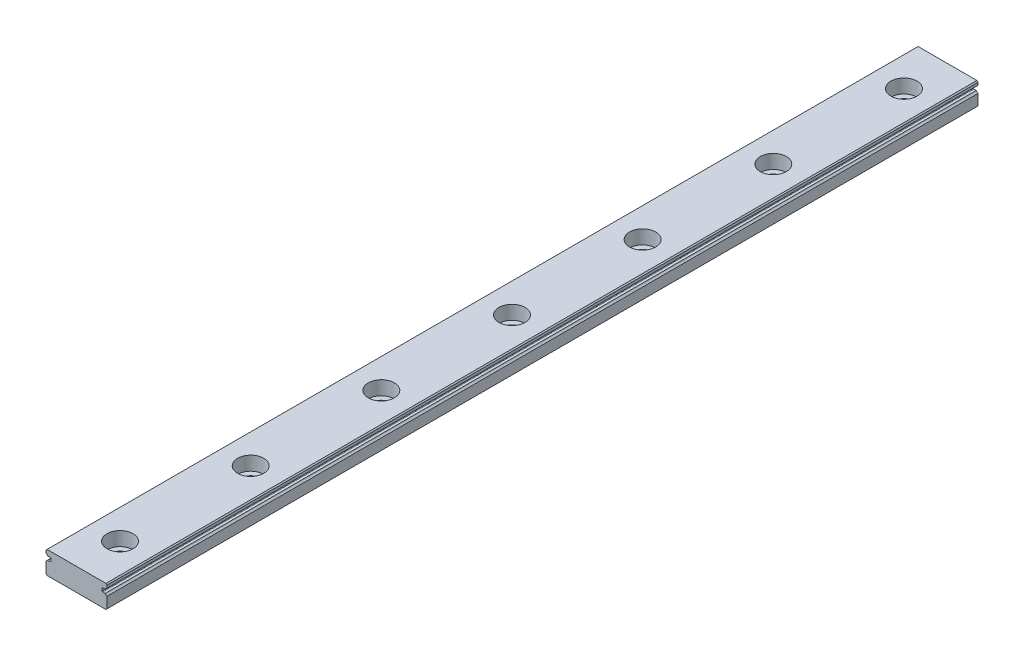
from build123d import *

# Parameters (mm, degrees)
SKETCH_1_W                   = 14
SKETCH_1_H                   = 200
EXTRUDE_1_DEPTH              = 5.2
CUT_EXTRUDE_1_DEPTH          = 201
CUT_EXTRUDE_2_DEPTH          = 201
CUT_EXTRUDE_3_DEPTH          = 201
CUT_EXTRUDE_4_DEPTH          = 201
HOLE_WIZARD_M3_1_D           = 3.5
HOLE_WIZARD_M3_1_DEPTH       = 5.2
HOLE_WIZARD_M3_1_CBORE_D     = 6
HOLE_WIZARD_M3_1_CBORE_DEPTH = 3.2
CHAMFER_1_SIZE               = 0.2475
FILLET_1_R                   = 0.14


with BuildPart() as part:
    # 草图1 → 凸台-拉伸1 (new body)
    with BuildSketch(Plane(origin=(0, 3.3, 0), x_dir=(1, 0, 0), z_dir=(0, 1, 0))):
        Rectangle(SKETCH_1_W, SKETCH_1_H)
    extrude(amount=-EXTRUDE_1_DEPTH)

    # 草图2 → 切除-拉伸1 (cut, through all)
    with BuildSketch(Plane(origin=(0, 0, -100), x_dir=(-1, 0, 0), z_dir=(0, 0, -1))):
        with BuildLine():
            Line((7, 1.23), (7, 2.44125))
            ThreePointArc((7, 2.44125), (6.766476308, 2.288808784), (6.593576466, 2.07))
            Line((6.593576466, 2.07), (5.893576466, 2.07))
            Line((5.893576466, 2.07), (5.893576466, 1.23))
            Line((5.893576466, 1.23), (7, 1.23))
        make_face()
    extrude(amount=-CUT_EXTRUDE_1_DEPTH, mode=Mode.SUBTRACT)

    # 草图3 → 切除-拉伸2 (cut, through all)
    with BuildSketch(Plane(origin=(0, 0, -100), x_dir=(-1, 0, 0), z_dir=(0, 0, -1))):
        with BuildLine():
            Line((7, 0.85875), (7, 1.23))
            Line((7, 1.23), (6.593576466, 1.23))
            ThreePointArc((6.593576466, 1.23), (6.766476308, 1.011191216), (7, 0.85875))
        make_face()
    extrude(amount=-CUT_EXTRUDE_2_DEPTH, mode=Mode.SUBTRACT)

    # 草图4 → 切除-拉伸3 (cut, through all)
    with BuildSketch(Plane(origin=(0, 0, -100), x_dir=(-1, 0, 0), z_dir=(0, 0, -1))):
        with BuildLine():
            Line((-7, 2.07), (-7, 0.85875))
            ThreePointArc((-7, 0.85875), (-6.766476308, 1.011191216), (-6.593576466, 1.23))
            Line((-6.593576466, 1.23), (-5.893576466, 1.23))
            Line((-5.893576466, 1.23), (-5.893576466, 2.07))
            Line((-5.893576466, 2.07), (-7, 2.07))
        make_face()
    extrude(amount=-CUT_EXTRUDE_3_DEPTH, mode=Mode.SUBTRACT)

    # 草图5 → 切除-拉伸4 (cut, through all)
    with BuildSketch(Plane(origin=(0, 0, -100), x_dir=(-1, 0, 0), z_dir=(0, 0, -1))):
        with BuildLine():
            Line((-7, 2.44125), (-7, 2.07))
            Line((-7, 2.07), (-6.593576466, 2.07))
            ThreePointArc((-6.593576466, 2.07), (-6.766476308, 2.288808784), (-7, 2.44125))
        make_face()
    extrude(amount=-CUT_EXTRUDE_4_DEPTH, mode=Mode.SUBTRACT)

    # M3 六角头机械螺钉的柱形沉头孔1
    with Locations(Plane(origin=(0, 3.3, 0), x_dir=(1, 0, 0), z_dir=(0, 1, 0))):
        with Locations((0, 90), (0, 60), (0, 30), (0, 0), (0, -30), (0, -60), (0, -90)):
            CounterBoreHole(HOLE_WIZARD_M3_1_D / 2, HOLE_WIZARD_M3_1_CBORE_D / 2, HOLE_WIZARD_M3_1_CBORE_DEPTH, depth=HOLE_WIZARD_M3_1_DEPTH)

    # 倒角1
    chamfer_1_edges = [part.edges().sort_by_distance(p)[0] for p in [
        (7, -1.9, 0),
        (-7, -1.9, 0),
        (7, 3.3, 0),
        (-7, 3.3, 0),
    ]]
    chamfer(chamfer_1_edges, length=CHAMFER_1_SIZE)

    # 圆角1
    fillet_1_edges = [part.edges().sort_by_distance(p)[0] for p in [
        (-5.893576466, 1.23, 0),
        (-5.893576466, 2.07, 0),
        (5.893576466, 2.07, 0),
        (5.893576466, 1.23, 0),
    ]]
    fillet(fillet_1_edges, radius=FILLET_1_R)


solid = part.part
